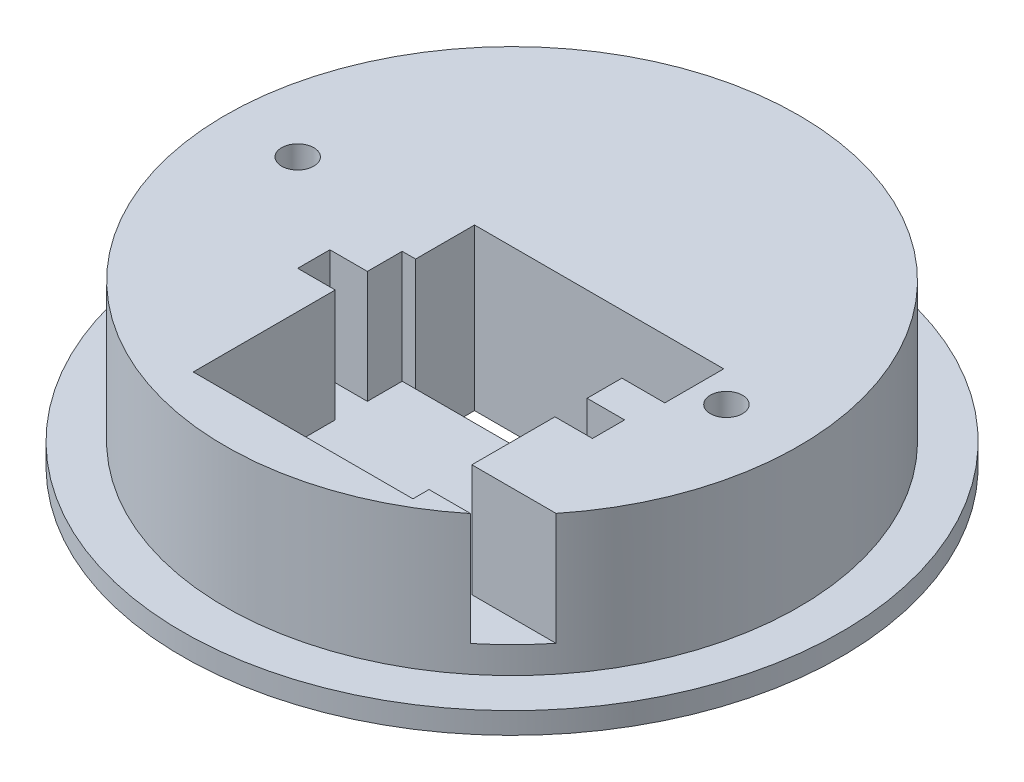
from build123d import *

# Parameters (mm, degrees)
ESQUISSE1_R             = 3
ESQUISSE1_W             = 25
ESQUISSE1_H             = 11
BOSS_EXTRU_1_DEPTH      = 30
ESQUISSE2_R             = 125
ESQUISSE2_R_2           = 53.5
ENL_V_MAT_EXTRU_1_DEPTH = 31
ESQUISSE8_R             = 61.5
ESQUISSE8_R_2           = 53.5
BOSS_EXTRU_2_DEPTH      = 4
ESQUISSE5_R             = 18
ENL_V_MAT_EXTRU_2_DEPTH = 11
ESQUISSE6_W             = 41
ESQUISSE6_H             = 39
ESQUISSE6_W_2           = 7
ESQUISSE6_H_2           = 6
ESQUISSE6_W_3           = 17
ESQUISSE6_H_3           = 8
ENL_V_MAT_EXTRU_3_DEPTH = 21
ESQUISSE7_W             = 36
ESQUISSE7_H             = 11
ENL_V_MAT_EXTRU_4_DEPTH = 11


with BuildPart() as part:
    # Esquisse1 → Boss.-Extru.1 (new body)
    with BuildSketch(Plane(origin=(0, 0, 0), x_dir=(1, 0, 0), z_dir=(0, 1, 0))):
        with BuildLine():
            ThreePointArc((68.106918153, 104.816256848), (54.23546739, 112.621108488), (39.484680574, 118.6))
            ThreePointArc((39.484680574, 118.6), (0, 85), (-39.484680574, 118.6))
            ThreePointArc((-39.484680574, 118.6), (-54.23546739, 112.621108488), (-68.106918153, 104.816256848))
            ThreePointArc((-68.106918153, 104.816256848), (-66.45567601, 52.996633158), (-117.343509488, 43.075524153))
            ThreePointArc((-117.343509488, 43.075524153), (-121.865989023, 27.815116745), (-124.412618383, 12.103734428))
            ThreePointArc((-124.412618383, 12.103734428), (-82.868872535, -18.914279386), (-106.840282387, -64.885699962))
            ThreePointArc((-106.840282387, -64.885699962), (-97.728935309, -77.936225232), (-87.033079415, -89.723146888))
            ThreePointArc((-87.033079415, -89.723146888), (-36.880117825, -76.582353772), (-15.884143503, -123.986668578))
            ThreePointArc((-15.884143503, -123.986668578), (0, -125), (15.884143503, -123.986668578))
            ThreePointArc((15.884143503, -123.986668578), (36.880117825, -76.582353772), (87.033079415, -89.723146888))
            ThreePointArc((87.033079415, -89.723146888), (97.728935309, -77.936225232), (106.840282387, -64.885699962))
            ThreePointArc((106.840282387, -64.885699962), (82.868872535, -18.914279386), (124.412618383, 12.103734428))
            ThreePointArc((124.412618383, 12.103734428), (121.865989023, 27.815116745), (117.343509488, 43.075524153))
            ThreePointArc((117.343509488, 43.075524153), (66.45567601, 52.996633158), (68.106918153, 104.816256848))
        make_face()
        with Locations((-40, 0)):
            Circle(ESQUISSE1_R, mode=Mode.SUBTRACT)
        with Locations((40, 0)):
            Circle(ESQUISSE1_R, mode=Mode.SUBTRACT)
        Rectangle(ESQUISSE1_W, ESQUISSE1_H, mode=Mode.SUBTRACT)
    extrude(amount=BOSS_EXTRU_1_DEPTH)

    # Esquisse2 → Enlèv. mat.-Extru.1 (cut, through all)
    with BuildSketch(Plane(origin=(0, 30, 0), x_dir=(1, 0, 0), z_dir=(0, 1, 0))):
        Circle(ESQUISSE2_R)
        Circle(ESQUISSE2_R_2, mode=Mode.SUBTRACT)
    extrude(amount=-ENL_V_MAT_EXTRU_1_DEPTH, mode=Mode.SUBTRACT)

    # Esquisse8 → Boss.-Extru.2 (add)
    with BuildSketch(Plane.XZ):
        Circle(ESQUISSE8_R)
        Circle(ESQUISSE8_R_2, mode=Mode.SUBTRACT)
    extrude(amount=-BOSS_EXTRU_2_DEPTH)

    # Esquisse5 → Enlèv. mat.-Extru.2 (cut)
    with BuildSketch(Plane(origin=(0, 0, 5.5), x_dir=(-1, 0, 0), z_dir=(0, 0, -1))):
        with Locations((-16, 19)):
            Circle(ESQUISSE5_R)
    extrude(amount=ENL_V_MAT_EXTRU_2_DEPTH, mode=Mode.SUBTRACT)

    # Esquisse6 → Enlèv. mat.-Extru.3 (cut)
    with BuildSketch(Plane(origin=(0, 30, 0), x_dir=(1, 0, 0), z_dir=(0, 1, 0))):
        with Locations((5.5, -25)):
            Rectangle(ESQUISSE6_W, ESQUISSE6_H)
        with Locations((-18.5, -15)):
            Rectangle(ESQUISSE6_W_2, ESQUISSE6_H_2)
        with Locations((29.5, -15)):
            Rectangle(ESQUISSE6_W_2, ESQUISSE6_H_2)
        with Locations((34.5, -37.5)):
            Rectangle(ESQUISSE6_W_3, ESQUISSE6_H_3)
    extrude(amount=-ENL_V_MAT_EXTRU_3_DEPTH, mode=Mode.SUBTRACT)

    # Esquisse7 → Enlèv. mat.-Extru.4 (cut)
    with BuildSketch(Plane(origin=(0, 30, 0), x_dir=(1, 0, 0), z_dir=(0, 1, 0))):
        with Locations((16, 0)):
            Rectangle(ESQUISSE7_W, ESQUISSE7_H)
    extrude(amount=-ENL_V_MAT_EXTRU_4_DEPTH, mode=Mode.SUBTRACT)


solid = part.part
